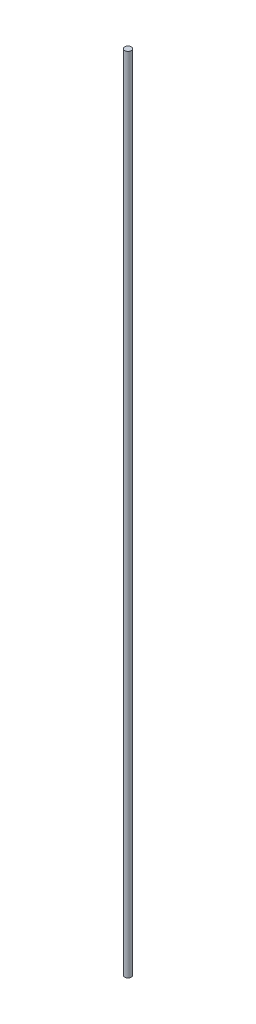
from build123d import *

# Parameters (mm, degrees)
SKETCH1_R           = 4
BOSS_EXTRUDE1_DEPTH = 974


with BuildPart() as part:
    # Sketch1 → Boss-Extrude1 (new body)
    with BuildSketch(Plane(origin=(0, 0, 0), x_dir=(1, 0, 0), z_dir=(0, 1, 0))):
        Circle(SKETCH1_R)
    extrude(amount=BOSS_EXTRUDE1_DEPTH)


solid = part.part
